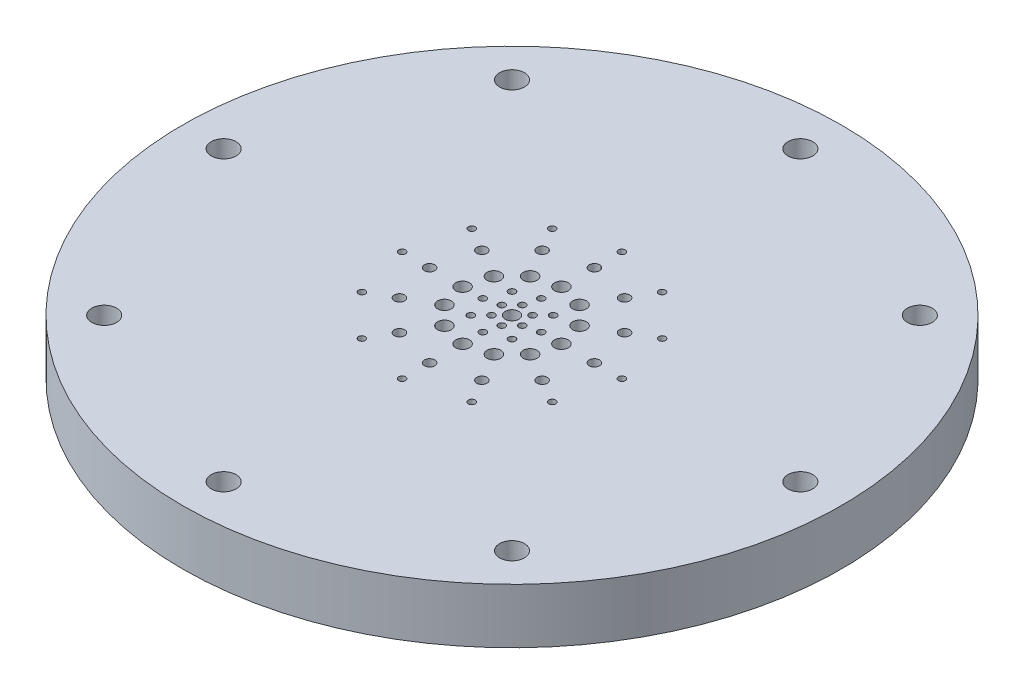
from build123d import *

# Parameters (mm, degrees)
SKETCH1_R                                      = 38.1
BOSS_EXTRUDE1_DEPTH                            = 6.35
CBORE_FOR_4_BUTTON_HEAD_CAP_SCREW1_D           = 2.8702
CBORE_FOR_4_BUTTON_HEAD_CAP_SCREW1_CBORE_D     = 4.826
CBORE_FOR_4_BUTTON_HEAD_CAP_SCREW1_CBORE_DEPTH = 1.905
CIRPATTERN1_COUNT                              = 8
SKETCH7_R                                      = 0.3937
SKETCH7_R_2                                    = 0.5969
SKETCH7_R_3                                    = 0.8001
SKETCH7_R_4                                    = 0.79375
CUT_EXTRUDE1_DEPTH                             = 7.35
CIRPATTERN3_COUNT                              = 12
CUT_EXTRUDE3_REACH                             = 8.35
SKETCH8_R                                      = 0.396875
CUT_EXTRUDE4_REACH                             = 8.35
SKETCH9_R                                      = 0.396875


with BuildPart() as part:
    # Sketch1 → Boss-Extrude1 (new body)
    with BuildSketch(Plane(origin=(0, 0, 0), x_dir=(1, 0, 0), z_dir=(0, 1, 0))):
        Circle(SKETCH1_R)
    extrude(amount=BOSS_EXTRUDE1_DEPTH)

    # CBORE for #4 Button Head Cap Screw1 (through all)
    with Locations(Plane(origin=(0, 0, 0), x_dir=(-1, 0, 0), z_dir=(0, -1, 0))):
        with Locations((0, -33.3375)):
            cbore_for_4_button_head_cap_screw1 = CounterBoreHole(CBORE_FOR_4_BUTTON_HEAD_CAP_SCREW1_D / 2, CBORE_FOR_4_BUTTON_HEAD_CAP_SCREW1_CBORE_D / 2, CBORE_FOR_4_BUTTON_HEAD_CAP_SCREW1_CBORE_DEPTH)

    # CirPattern1: CBORE for #4 Button Head Cap Screw1 ×8 about axis
    cirpattern1_axis = Axis((0, 0, 0), (0, 1, 0))
    for i in range(1, CIRPATTERN1_COUNT):
        add(cbore_for_4_button_head_cap_screw1.rotate(cirpattern1_axis, i * 360 / CIRPATTERN1_COUNT), mode=Mode.SUBTRACT)

    # Sketch7 → Cut-Extrude1 (cut, through all)
    with BuildSketch(Plane.XZ):
        with Locations((0, 12.7)):
            Circle(SKETCH7_R)
        with Locations((0, 9.525)):
            Circle(SKETCH7_R_2)
        with Locations((0, 5.715)):
            Circle(SKETCH7_R_3)
        Circle(SKETCH7_R_4)
    cut_extrude1 = extrude(amount=-CUT_EXTRUDE1_DEPTH, mode=Mode.SUBTRACT)

    # CirPattern3: Cut-Extrude1 ×12 about axis
    cirpattern3_axis = Axis((0, 0, 0), (0, 1, 0))
    for i in range(1, CIRPATTERN3_COUNT):
        add(cut_extrude1.rotate(cirpattern3_axis, i * 360 / CIRPATTERN3_COUNT), mode=Mode.SUBTRACT)

    # Sketch8 → Cut-Extrude3 (cut, up to next)
    with BuildSketch(Plane(origin=(0, 6.35, 0), x_dir=(1, 0, 0), z_dir=(0, 1, 0)), mode=Mode.PRIVATE) as cut_extrude3_sk1:
        with Locations((3.368817958, 0)):
            Circle(SKETCH8_R)
    cut_extrude3_tool1 = extrude(cut_extrude3_sk1.sketch, amount=-CUT_EXTRUDE3_REACH, mode=Mode.PRIVATE) & part.part
    add(cut_extrude3_tool1.solids().sort_by_distance((3.368818, 6.35, 0))[0], mode=Mode.SUBTRACT)
    # Sketch8 → Cut-Extrude3 (cut, up to next)
    with BuildSketch(Plane(origin=(0, 6.35, 0), x_dir=(1, 0, 0), z_dir=(0, 1, 0)), mode=Mode.PRIVATE) as cut_extrude3_sk2:
        with Locations((2.382114023, -2.382114023)):
            Circle(SKETCH8_R)
    cut_extrude3_tool2 = extrude(cut_extrude3_sk2.sketch, amount=-CUT_EXTRUDE3_REACH, mode=Mode.PRIVATE) & part.part
    add(cut_extrude3_tool2.solids().sort_by_distance((2.382114, 6.35, 2.382114))[0], mode=Mode.SUBTRACT)
    # Sketch8 → Cut-Extrude3 (cut, up to next)
    with BuildSketch(Plane(origin=(0, 6.35, 0), x_dir=(1, 0, 0), z_dir=(0, 1, 0)), mode=Mode.PRIVATE) as cut_extrude3_sk3:
        with Locations((0, -3.368817958)):
            Circle(SKETCH8_R)
    cut_extrude3_tool3 = extrude(cut_extrude3_sk3.sketch, amount=-CUT_EXTRUDE3_REACH, mode=Mode.PRIVATE) & part.part
    add(cut_extrude3_tool3.solids().sort_by_distance((0, 6.35, 3.368818))[0], mode=Mode.SUBTRACT)
    # Sketch8 → Cut-Extrude3 (cut, up to next)
    with BuildSketch(Plane(origin=(0, 6.35, 0), x_dir=(1, 0, 0), z_dir=(0, 1, 0)), mode=Mode.PRIVATE) as cut_extrude3_sk4:
        with Locations((-2.382114023, -2.382114023)):
            Circle(SKETCH8_R)
    cut_extrude3_tool4 = extrude(cut_extrude3_sk4.sketch, amount=-CUT_EXTRUDE3_REACH, mode=Mode.PRIVATE) & part.part
    add(cut_extrude3_tool4.solids().sort_by_distance((-2.382114, 6.35, 2.382114))[0], mode=Mode.SUBTRACT)
    # Sketch8 → Cut-Extrude3 (cut, up to next)
    with BuildSketch(Plane(origin=(0, 6.35, 0), x_dir=(1, 0, 0), z_dir=(0, 1, 0)), mode=Mode.PRIVATE) as cut_extrude3_sk5:
        with Locations((-3.368817958, 0)):
            Circle(SKETCH8_R)
    cut_extrude3_tool5 = extrude(cut_extrude3_sk5.sketch, amount=-CUT_EXTRUDE3_REACH, mode=Mode.PRIVATE) & part.part
    add(cut_extrude3_tool5.solids().sort_by_distance((-3.368818, 6.35, 0))[0], mode=Mode.SUBTRACT)
    # Sketch8 → Cut-Extrude3 (cut, up to next)
    with BuildSketch(Plane(origin=(0, 6.35, 0), x_dir=(1, 0, 0), z_dir=(0, 1, 0)), mode=Mode.PRIVATE) as cut_extrude3_sk6:
        with Locations((-2.382114023, 2.382114023)):
            Circle(SKETCH8_R)
    cut_extrude3_tool6 = extrude(cut_extrude3_sk6.sketch, amount=-CUT_EXTRUDE3_REACH, mode=Mode.PRIVATE) & part.part
    add(cut_extrude3_tool6.solids().sort_by_distance((-2.382114, 6.35, -2.382114))[0], mode=Mode.SUBTRACT)
    # Sketch8 → Cut-Extrude3 (cut, up to next)
    with BuildSketch(Plane(origin=(0, 6.35, 0), x_dir=(1, 0, 0), z_dir=(0, 1, 0)), mode=Mode.PRIVATE) as cut_extrude3_sk7:
        with Locations((0, 3.368817958)):
            Circle(SKETCH8_R)
    cut_extrude3_tool7 = extrude(cut_extrude3_sk7.sketch, amount=-CUT_EXTRUDE3_REACH, mode=Mode.PRIVATE) & part.part
    add(cut_extrude3_tool7.solids().sort_by_distance((0, 6.35, -3.368818))[0], mode=Mode.SUBTRACT)
    # Sketch8 → Cut-Extrude3 (cut, up to next)
    with BuildSketch(Plane(origin=(0, 6.35, 0), x_dir=(1, 0, 0), z_dir=(0, 1, 0)), mode=Mode.PRIVATE) as cut_extrude3_sk8:
        with Locations((2.382114023, 2.382114023)):
            Circle(SKETCH8_R)
    cut_extrude3_tool8 = extrude(cut_extrude3_sk8.sketch, amount=-CUT_EXTRUDE3_REACH, mode=Mode.PRIVATE) & part.part
    add(cut_extrude3_tool8.solids().sort_by_distance((2.382114, 6.35, -2.382114))[0], mode=Mode.SUBTRACT)

    # Sketch9 → Cut-Extrude4 (cut, up to next)
    with BuildSketch(Plane(origin=(0, 6.35, 0), x_dir=(1, 0, 0), z_dir=(0, 1, 0)), mode=Mode.PRIVATE) as cut_extrude4_sk1:
        with Locations((1.187739958, 1.187739958)):
            Circle(SKETCH9_R)
    cut_extrude4_tool1 = extrude(cut_extrude4_sk1.sketch, amount=-CUT_EXTRUDE4_REACH, mode=Mode.PRIVATE) & part.part
    add(cut_extrude4_tool1.solids().sort_by_distance((1.18774, 6.35, -1.18774))[0], mode=Mode.SUBTRACT)
    # Sketch9 → Cut-Extrude4 (cut, up to next)
    with BuildSketch(Plane(origin=(0, 6.35, 0), x_dir=(1, 0, 0), z_dir=(0, 1, 0)), mode=Mode.PRIVATE) as cut_extrude4_sk2:
        with Locations((1.622482956, -0.434742998)):
            Circle(SKETCH9_R)
    cut_extrude4_tool2 = extrude(cut_extrude4_sk2.sketch, amount=-CUT_EXTRUDE4_REACH, mode=Mode.PRIVATE) & part.part
    add(cut_extrude4_tool2.solids().sort_by_distance((1.622483, 6.35, 0.434743))[0], mode=Mode.SUBTRACT)
    # Sketch9 → Cut-Extrude4 (cut, up to next)
    with BuildSketch(Plane(origin=(0, 6.35, 0), x_dir=(1, 0, 0), z_dir=(0, 1, 0)), mode=Mode.PRIVATE) as cut_extrude4_sk3:
        with Locations((0.434742998, -1.622482956)):
            Circle(SKETCH9_R)
    cut_extrude4_tool3 = extrude(cut_extrude4_sk3.sketch, amount=-CUT_EXTRUDE4_REACH, mode=Mode.PRIVATE) & part.part
    add(cut_extrude4_tool3.solids().sort_by_distance((0.434743, 6.35, 1.622483))[0], mode=Mode.SUBTRACT)
    # Sketch9 → Cut-Extrude4 (cut, up to next)
    with BuildSketch(Plane(origin=(0, 6.35, 0), x_dir=(1, 0, 0), z_dir=(0, 1, 0)), mode=Mode.PRIVATE) as cut_extrude4_sk4:
        with Locations((-1.187739958, -1.187739958)):
            Circle(SKETCH9_R)
    cut_extrude4_tool4 = extrude(cut_extrude4_sk4.sketch, amount=-CUT_EXTRUDE4_REACH, mode=Mode.PRIVATE) & part.part
    add(cut_extrude4_tool4.solids().sort_by_distance((-1.18774, 6.35, 1.18774))[0], mode=Mode.SUBTRACT)
    # Sketch9 → Cut-Extrude4 (cut, up to next)
    with BuildSketch(Plane(origin=(0, 6.35, 0), x_dir=(1, 0, 0), z_dir=(0, 1, 0)), mode=Mode.PRIVATE) as cut_extrude4_sk5:
        with Locations((-1.622482956, 0.434742998)):
            Circle(SKETCH9_R)
    cut_extrude4_tool5 = extrude(cut_extrude4_sk5.sketch, amount=-CUT_EXTRUDE4_REACH, mode=Mode.PRIVATE) & part.part
    add(cut_extrude4_tool5.solids().sort_by_distance((-1.622483, 6.35, -0.434743))[0], mode=Mode.SUBTRACT)
    # Sketch9 → Cut-Extrude4 (cut, up to next)
    with BuildSketch(Plane(origin=(0, 6.35, 0), x_dir=(1, 0, 0), z_dir=(0, 1, 0)), mode=Mode.PRIVATE) as cut_extrude4_sk6:
        with Locations((-0.434742998, 1.622482956)):
            Circle(SKETCH9_R)
    cut_extrude4_tool6 = extrude(cut_extrude4_sk6.sketch, amount=-CUT_EXTRUDE4_REACH, mode=Mode.PRIVATE) & part.part
    add(cut_extrude4_tool6.solids().sort_by_distance((-0.434743, 6.35, -1.622483))[0], mode=Mode.SUBTRACT)


solid = part.part
